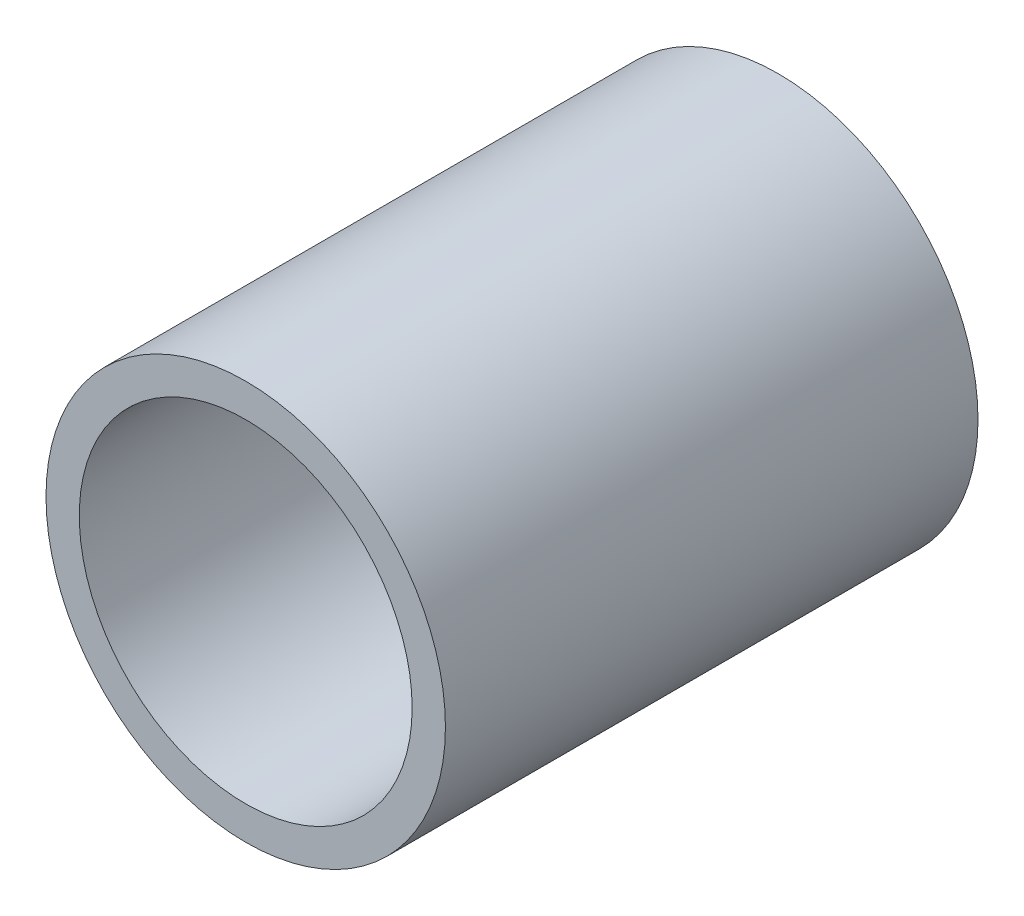
from build123d import *

# Parameters (mm, degrees)
SKETCH1_R           = 3
BOSS_EXTRUDE1_DEPTH = 8
SKETCH2_R           = 2.5
CUT_EXTRUDE1_DEPTH  = 7


with BuildPart() as part:
    # Sketch1 → Boss-Extrude1 (new body)
    with BuildSketch(Plane.XY):
        Circle(SKETCH1_R)
    extrude(amount=BOSS_EXTRUDE1_DEPTH)

    # Sketch2 → Cut-Extrude1 (cut)
    with BuildSketch(Plane.XY.offset(8)):
        Circle(SKETCH2_R)
    extrude(amount=-CUT_EXTRUDE1_DEPTH, mode=Mode.SUBTRACT)


solid = part.part
